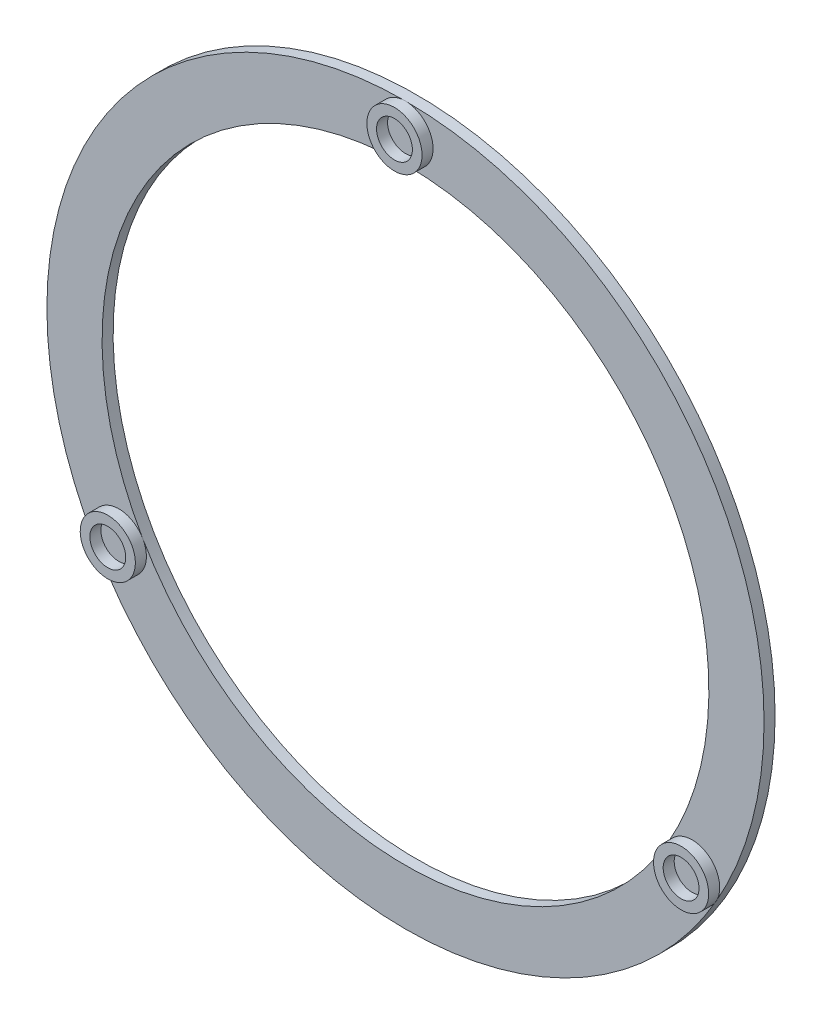
from build123d import *

# Parameters (mm, degrees)
SKETCH1_R           = 325
SKETCH1_R_2         = 275
BOSS_EXTRUDE1_DEPTH = 10
SKETCH2_R           = 25
SKETCH2_R_2         = 16.25
BOSS_EXTRUDE2_DEPTH = 10


with BuildPart() as part:
    # Sketch1 → Boss-Extrude1 (new body)
    with BuildSketch(Plane.XY):
        Circle(SKETCH1_R)
        Circle(SKETCH1_R_2, mode=Mode.SUBTRACT)
    extrude(amount=BOSS_EXTRUDE1_DEPTH)

    # Sketch2 → Boss-Extrude2 (add)
    with BuildSketch(Plane.XY.offset(10)):
        with Locations((0, 300)):
            Circle(SKETCH2_R)
        with Locations((0, 300)):
            Circle(SKETCH2_R_2, mode=Mode.SUBTRACT)
        with Locations((259.807621135, -150)):
            Circle(SKETCH2_R)
        with Locations((259.807621135, -150)):
            Circle(SKETCH2_R_2, mode=Mode.SUBTRACT)
        with Locations((-259.807621135, -150)):
            Circle(SKETCH2_R)
        with Locations((-259.807621135, -150)):
            Circle(SKETCH2_R_2, mode=Mode.SUBTRACT)
    extrude(amount=BOSS_EXTRUDE2_DEPTH)


solid = part.part
